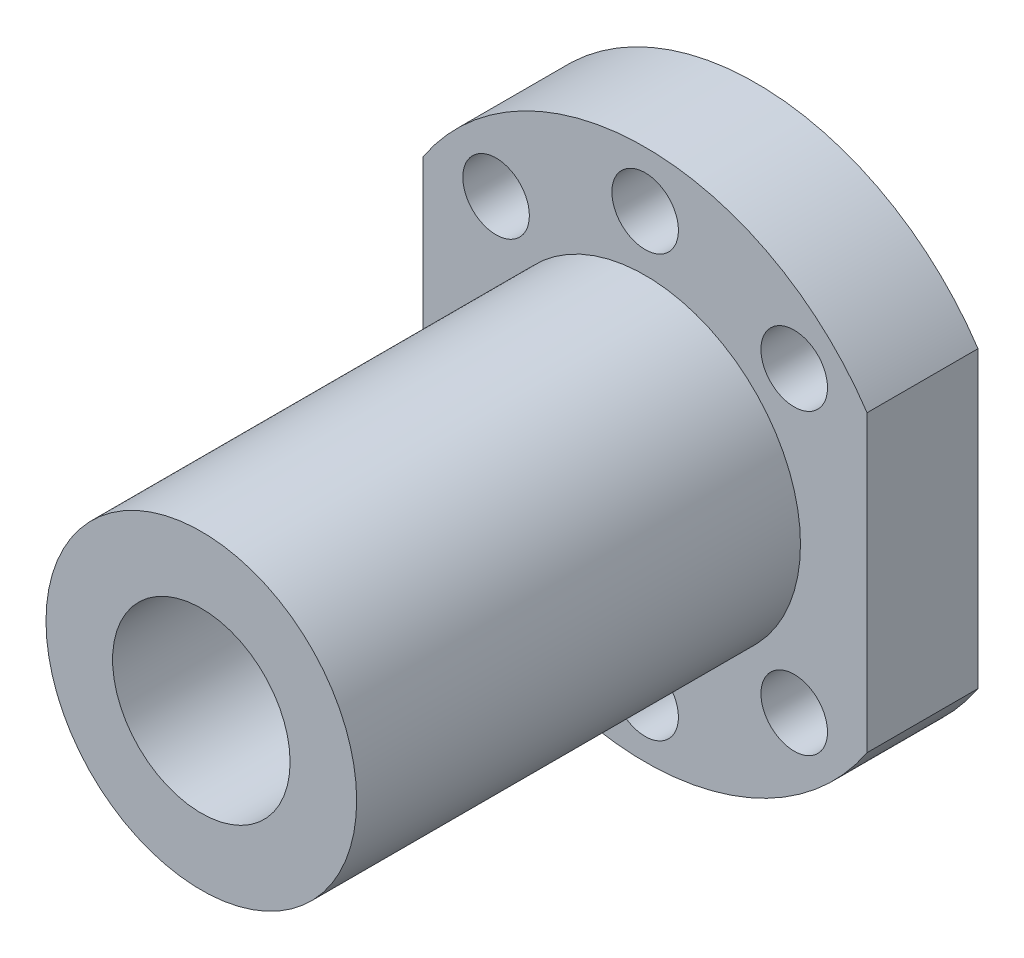
from build123d import *

# Parameters (mm, degrees)
SKETCH1_R      = 3
EXTRUDE4_DEPTH = 10
EXTRUDE5_DEPTH = 50


with BuildPart() as part:
    # Sketch1 → Extrude4 (new body)
    with BuildSketch(Plane.XY):
        with BuildLine():
            Line((-20, 13.266499161), (-20, -13.266499161))
            ThreePointArc((-20, -13.266499161), (0, -24), (20, -13.266499161))
            Line((20, -13.266499161), (20, 13.266499161))
            ThreePointArc((20, 13.266499161), (0, 24), (-20, 13.266499161))
        make_face()
        with BuildLine():
            ThreePointArc((-9.899494937, 9.899494937), (-5.357568053, 12.934313455), (0, 14))
            ThreePointArc((0, 14), (5.357568053, 12.934313455), (9.899494937, 9.899494937))
            ThreePointArc((9.899494937, 9.899494937), (14, 0), (9.899494937, -9.899494937))
            ThreePointArc((9.899494937, -9.899494937), (5.357568053, -12.934313455), (0, -14))
            ThreePointArc((0, -14), (-5.357568053, -12.934313455), (-9.899494937, -9.899494937))
            ThreePointArc((-9.899494937, -9.899494937), (-14, 0), (-9.899494937, 9.899494937))
        make_face(mode=Mode.SUBTRACT)
        with Locations((-13.435028843, 13.435028843)):
            Circle(SKETCH1_R, mode=Mode.SUBTRACT)
        with Locations((0, 19)):
            Circle(SKETCH1_R, mode=Mode.SUBTRACT)
        with Locations((13.435028843, 13.435028843)):
            Circle(SKETCH1_R, mode=Mode.SUBTRACT)
        with Locations((-13.435028843, -13.435028843)):
            Circle(SKETCH1_R, mode=Mode.SUBTRACT)
        with Locations((0, -19)):
            Circle(SKETCH1_R, mode=Mode.SUBTRACT)
        with Locations((13.435028843, -13.435028843)):
            Circle(SKETCH1_R, mode=Mode.SUBTRACT)
    extrude(amount=EXTRUDE4_DEPTH)

    # Sketch1_5 → Extrude5 (add)
    with BuildSketch(Plane.XY):
        with BuildLine():
            Line((0, 14), (0, 8))
            ThreePointArc((0, 8), (3.061467459, 7.39103626), (5.656854249, 5.656854249))
            Line((5.656854249, 5.656854249), (9.899494937, 9.899494937))
            ThreePointArc((9.899494937, 9.899494937), (5.357568053, 12.934313455), (0, 14))
        make_face()
        with BuildLine():
            ThreePointArc((-5.656854249, 5.656854249), (-3.061467459, 7.39103626), (0, 8))
            Line((0, 8), (0, 14))
            ThreePointArc((0, 14), (-5.357568053, 12.934313455), (-9.899494937, 9.899494937))
            Line((-9.899494937, 9.899494937), (-5.656854249, 5.656854249))
        make_face()
        with BuildLine():
            Line((9.899494937, 9.899494937), (5.656854249, 5.656854249))
            ThreePointArc((5.656854249, 5.656854249), (7.39103626, 3.061467459), (8, 0))
            Line((8, 0), (14, 0))
            ThreePointArc((14, 0), (12.934313455, 5.357568053), (9.899494937, 9.899494937))
        make_face()
        with BuildLine():
            ThreePointArc((8, 0), (7.39103626, -3.061467459), (5.656854249, -5.656854249))
            Line((5.656854249, -5.656854249), (9.899494937, -9.899494937))
            ThreePointArc((9.899494937, -9.899494937), (12.934313455, -5.357568053), (14, 0))
            Line((14, 0), (8, 0))
        make_face()
        with BuildLine():
            ThreePointArc((5.656854249, -5.656854249), (3.061467459, -7.39103626), (0, -8))
            Line((0, -8), (0, -14))
            ThreePointArc((0, -14), (5.357568053, -12.934313455), (9.899494937, -9.899494937))
            Line((9.899494937, -9.899494937), (5.656854249, -5.656854249))
        make_face()
        with BuildLine():
            Line((0, -14), (0, -8))
            ThreePointArc((0, -8), (-3.061467459, -7.39103626), (-5.656854249, -5.656854249))
            Line((-5.656854249, -5.656854249), (-9.899494937, -9.899494937))
            ThreePointArc((-9.899494937, -9.899494937), (-5.357568053, -12.934313455), (0, -14))
        make_face()
        with BuildLine():
            Line((-9.899494937, -9.899494937), (-5.656854249, -5.656854249))
            ThreePointArc((-5.656854249, -5.656854249), (-7.39103626, -3.061467459), (-8, 0))
            Line((-8, 0), (-14, 0))
            ThreePointArc((-14, 0), (-12.934313455, -5.357568053), (-9.899494937, -9.899494937))
        make_face()
        with BuildLine():
            ThreePointArc((-8, 0), (-7.39103626, 3.061467459), (-5.656854249, 5.656854249))
            Line((-5.656854249, 5.656854249), (-9.899494937, 9.899494937))
            ThreePointArc((-9.899494937, 9.899494937), (-12.934313455, 5.357568053), (-14, 0))
            Line((-14, 0), (-8, 0))
        make_face()
    extrude(amount=EXTRUDE5_DEPTH)


solid = part.part
